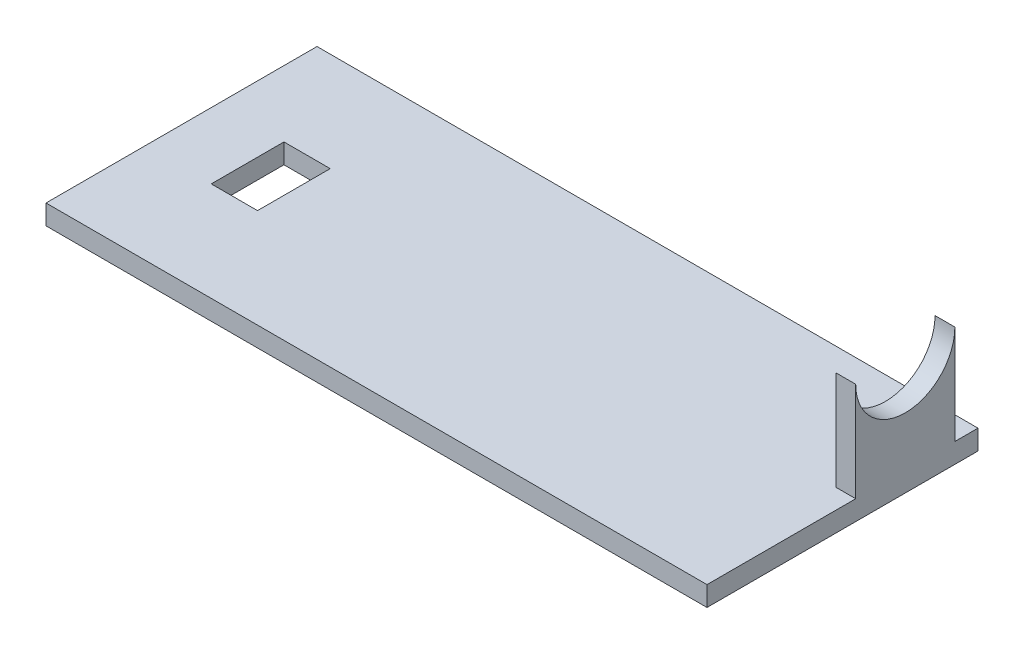
from build123d import *

# Parameters (mm, degrees)
ESQUISSE1_W             = 100
ESQUISSE1_H             = 41
BOSS_EXTRU_1_DEPTH      = 3
ESQUISSE2_W             = 7
ESQUISSE2_H             = 11
ENL_V_MAT_EXTRU_2_DEPTH = 3
ESQUISSE3_W             = 3
ESQUISSE3_H             = 15
BOSS_EXTRU_2_DEPTH      = 18
ESQUISSE4_R             = 7.5
ENL_V_MAT_EXTRU_3_DEPTH = 6


with BuildPart() as part:
    # Esquisse1 → Boss.-Extru.1 (new body)
    with BuildSketch(Plane(origin=(0, 0, 0), x_dir=(1, 0, 0), z_dir=(0, 1, 0))):
        Rectangle(ESQUISSE1_W, ESQUISSE1_H)
    extrude(amount=BOSS_EXTRU_1_DEPTH)

    # Esquisse2 → Enlèv. mat.-Extru.2 (cut)
    with BuildSketch(Plane(origin=(0, 3, 0), x_dir=(1, 0, 0), z_dir=(0, 1, 0))):
        with Locations((-36.5, 0)):
            Rectangle(ESQUISSE2_W, ESQUISSE2_H)
    extrude(amount=-ENL_V_MAT_EXTRU_2_DEPTH, mode=Mode.SUBTRACT)

    # Esquisse3 → Boss.-Extru.2 (add)
    with BuildSketch(Plane.XZ):
        with Locations((48.5, -9.5)):
            Rectangle(ESQUISSE3_W, ESQUISSE3_H)
    extrude(amount=-BOSS_EXTRU_2_DEPTH)

    # Esquisse4 → Enlèv. mat.-Extru.3 (cut)
    with BuildSketch(Plane(origin=(50, 0, 0), x_dir=(0, 0, -1), z_dir=(1, 0, 0))):
        with Locations((9.5, 18)):
            Circle(ESQUISSE4_R)
    extrude(amount=-ENL_V_MAT_EXTRU_3_DEPTH, mode=Mode.SUBTRACT)


solid = part.part
